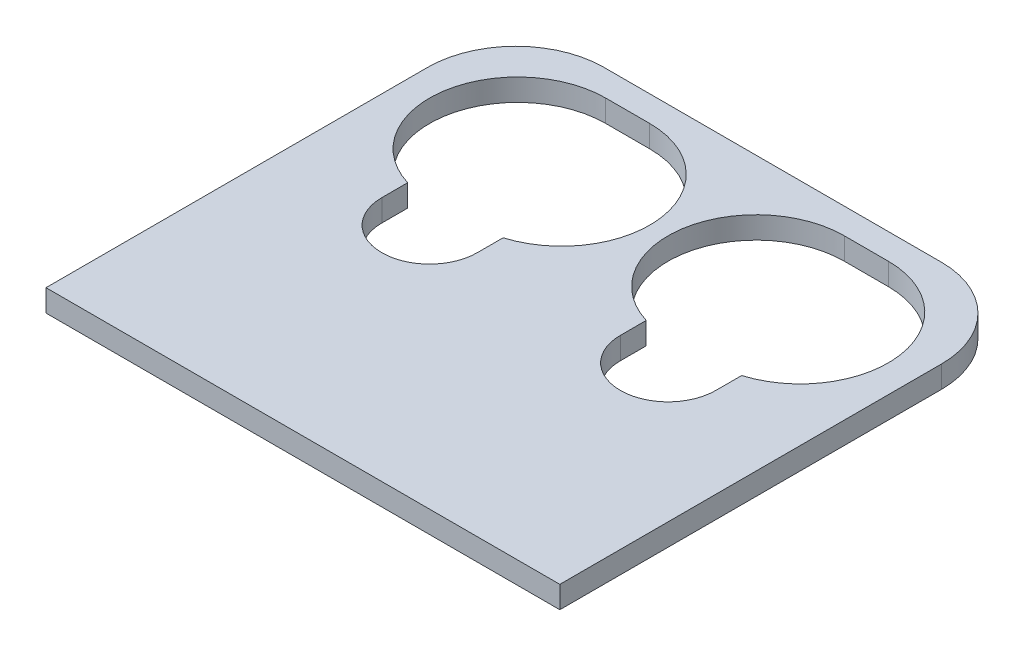
from build123d import *

# Parameters (mm, degrees)
SKETCH1_W               = 70
SKETCH1_H               = 67
BOSS_EXTRUDE1_DEPTH     = 3
SKETCH5_W               = 70
SKETCH5_H               = 3
CUT_EXTRUDE4_DEPTH      = 1
CUT_EXTRUDE4_DEPTH_BACK = 4
FILLET1_R               = 12
CUT_EXTRUDE1_START      = -4
SKETCH2_R               = 6.5
CUT_EXTRUDE1_DEPTH      = 5
CUT_EXTRUDE2_START      = -4
CUT_EXTRUDE2_DEPTH      = 5
CUT_EXTRUDE3_START      = -4
SKETCH4_W               = 13
SKETCH4_H               = 8.828059947
CUT_EXTRUDE3_DEPTH      = 5


with BuildPart() as part:
    # Sketch1 → Boss-Extrude1 (new body)
    with BuildSketch(Plane(origin=(0, 0, 0), x_dir=(1, 0, 0), z_dir=(0, 1, 0))):
        Rectangle(SKETCH1_W, SKETCH1_H)
    extrude(amount=BOSS_EXTRUDE1_DEPTH)

    # Sketch5 → Cut-Extrude4 (cut, two sides)
    with BuildSketch(Plane(origin=(0, 3, 0), x_dir=(1, 0, 0), z_dir=(0, 1, 0))) as cut_extrude4_sk:
        with Locations((0, 32)):
            Rectangle(SKETCH5_W, SKETCH5_H)
    extrude(amount=CUT_EXTRUDE4_DEPTH, mode=Mode.SUBTRACT)
    extrude(cut_extrude4_sk.sketch, amount=-CUT_EXTRUDE4_DEPTH_BACK, mode=Mode.SUBTRACT)

    # Fillet1
    fillet1_edges = [part.edges().sort_by_distance(p)[0] for p in [
        (-35, 1.5, -30.5),
        (35, 1.5, -30.5),
    ]]
    fillet(fillet1_edges, radius=FILLET1_R)

    # Sketch2 → Cut-Extrude1 (cut)
    with BuildSketch(Plane(origin=(0, 3, 0), x_dir=(1, 0, 0), z_dir=(0, 1, 0)).offset(CUT_EXTRUDE1_START)):
        with Locations((-16.25, 0)):
            Circle(SKETCH2_R)
    cut_extrude1 = extrude(amount=CUT_EXTRUDE1_DEPTH, mode=Mode.SUBTRACT)

    # Sketch3 → Cut-Extrude2 (cut)
    with BuildSketch(Plane(origin=(0, 3, 0), x_dir=(1, 0, 0), z_dir=(0, 1, 0)).offset(CUT_EXTRUDE2_START)):
        with BuildLine():
            Line((-19.25, 27), (-13.25, 27))
            ThreePointArc((-13.25, 27), (-1.25, 15), (-13.25, 3))
            Line((-13.25, 3), (-19.25, 3))
            ThreePointArc((-19.25, 3), (-31.25, 15), (-19.25, 27))
        make_face()
    cut_extrude2 = extrude(amount=CUT_EXTRUDE2_DEPTH, mode=Mode.SUBTRACT)

    # Sketch4 → Cut-Extrude3 (cut)
    with BuildSketch(Plane(origin=(0, 3, 0), x_dir=(1, 0, 0), z_dir=(0, 1, 0)).offset(CUT_EXTRUDE3_START)):
        with Locations((-16.25, 4.414029973)):
            Rectangle(SKETCH4_W, SKETCH4_H)
    cut_extrude3 = extrude(amount=CUT_EXTRUDE3_DEPTH, mode=Mode.SUBTRACT)

    # Mirror1: Cut-Extrude1, Cut-Extrude2, Cut-Extrude3 across plane
    add(cut_extrude1.mirror(Plane(origin=(0, 0, 0), x_dir=(0, 0, 1), z_dir=(1, 0, 0))), mode=Mode.SUBTRACT)
    add(cut_extrude2.mirror(Plane(origin=(0, 0, 0), x_dir=(0, 0, 1), z_dir=(1, 0, 0))), mode=Mode.SUBTRACT)
    add(cut_extrude3.mirror(Plane(origin=(0, 0, 0), x_dir=(0, 0, 1), z_dir=(1, 0, 0))), mode=Mode.SUBTRACT)


solid = part.part
